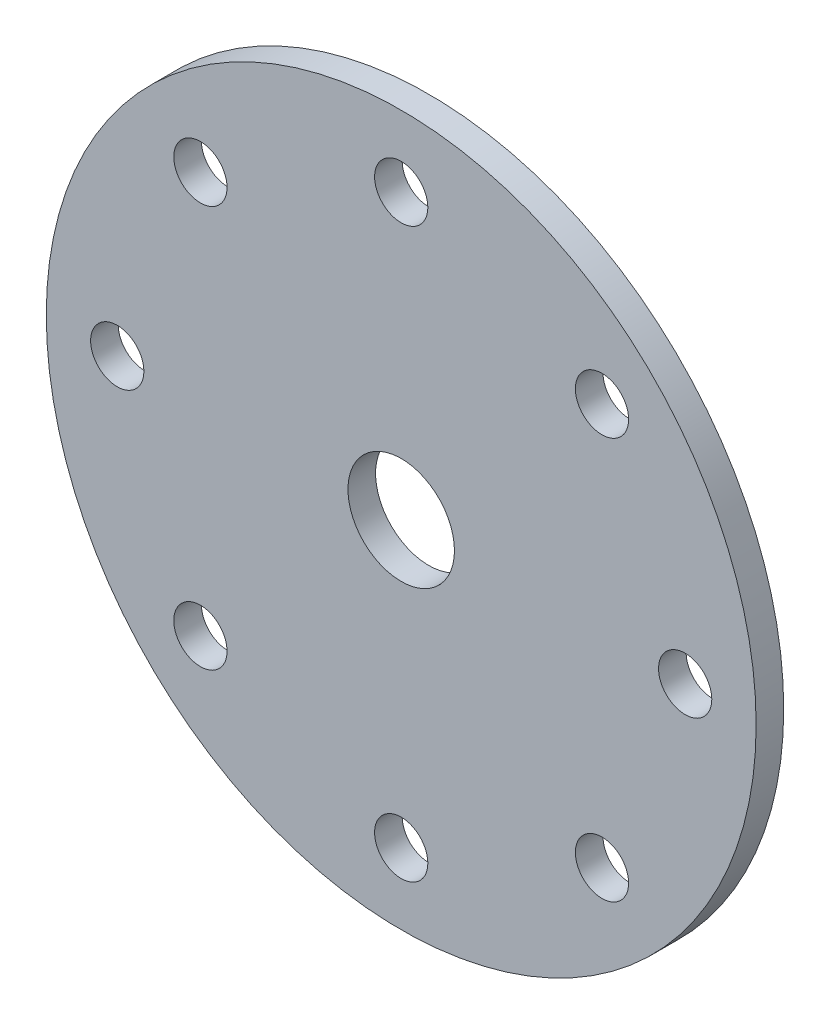
from build123d import *

# Parameters (mm, degrees)
SKETCH1_R        = 63.5
SKETCH1_R_2      = 9.525
SKETCH1_R_3      = 4.7625
ROTOR_DISC_DEPTH = 4.93522


with BuildPart() as part:
    # Sketch1 → Rotor Disc (new body)
    with BuildSketch(Plane.XY):
        Circle(SKETCH1_R)
        Circle(SKETCH1_R_2, mode=Mode.SUBTRACT)
        with Locations((0, 50.8)):
            Circle(SKETCH1_R_3, mode=Mode.SUBTRACT)
        with Locations((35.921024484, 35.921024484)):
            Circle(SKETCH1_R_3, mode=Mode.SUBTRACT)
        with Locations((50.8, 0)):
            Circle(SKETCH1_R_3, mode=Mode.SUBTRACT)
        with Locations((35.921024484, -35.921024484)):
            Circle(SKETCH1_R_3, mode=Mode.SUBTRACT)
        with Locations((0, -50.8)):
            Circle(SKETCH1_R_3, mode=Mode.SUBTRACT)
        with Locations((-35.921024484, -35.921024484)):
            Circle(SKETCH1_R_3, mode=Mode.SUBTRACT)
        with Locations((-50.8, 0)):
            Circle(SKETCH1_R_3, mode=Mode.SUBTRACT)
        with Locations((-35.921024484, 35.921024484)):
            Circle(SKETCH1_R_3, mode=Mode.SUBTRACT)
    extrude(amount=ROTOR_DISC_DEPTH)


solid = part.part
